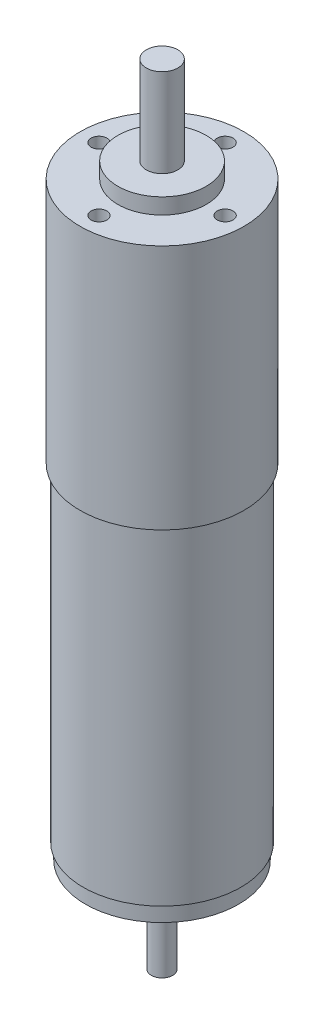
from build123d import *

# Parameters (mm, degrees)
ESQUISSE2_R             = 1.692758077
BOSS_EXTRU_1_DEPTH      = 15
ESQUISSE3_R             = 4
BOSS_EXTRU_2_DEPTH      = 2.5
ESQUISSE4_R             = 1.25
ENL_V_MAT_EXTRU_1_DEPTH = 5


with BuildPart() as part:
    # Esquisse1 → Révolution1 (revolve)
    with BuildSketch(Plane.XY):
        Polygon((0, 0), (12.15, 0), (12.15, 2.5), (12.5, 2.5), (12.5, 54.5), (13, 54.5), (13, 93.5), (7, 93.5), (7, 96), (2.5, 96), (2.5, 110), (0, 110), align=None)
    revolve(axis=Axis((0, 0, 0), (0, 1, 0)))

    # Esquisse2 → Boss.-Extru.1 (add)
    with BuildSketch(Plane.XZ):
        Circle(ESQUISSE2_R)
    extrude(amount=BOSS_EXTRU_1_DEPTH)

    # Esquisse3 → Boss.-Extru.2 (add)
    with BuildSketch(Plane.XZ):
        Circle(ESQUISSE3_R)
    extrude(amount=BOSS_EXTRU_2_DEPTH)

    # Esquisse4 → Enlèv. mat.-Extru.1 (cut)
    with BuildSketch(Plane(origin=(0, 93.5, 0), x_dir=(1, 0, 0), z_dir=(0, 1, 0))):
        with Locations((0, 10)):
            Circle(ESQUISSE4_R)
        with Locations((10, 0)):
            Circle(ESQUISSE4_R)
        with Locations((0, -10)):
            Circle(ESQUISSE4_R)
        with Locations((-10, 0)):
            Circle(ESQUISSE4_R)
    extrude(amount=-ENL_V_MAT_EXTRU_1_DEPTH, mode=Mode.SUBTRACT)


solid = part.part
